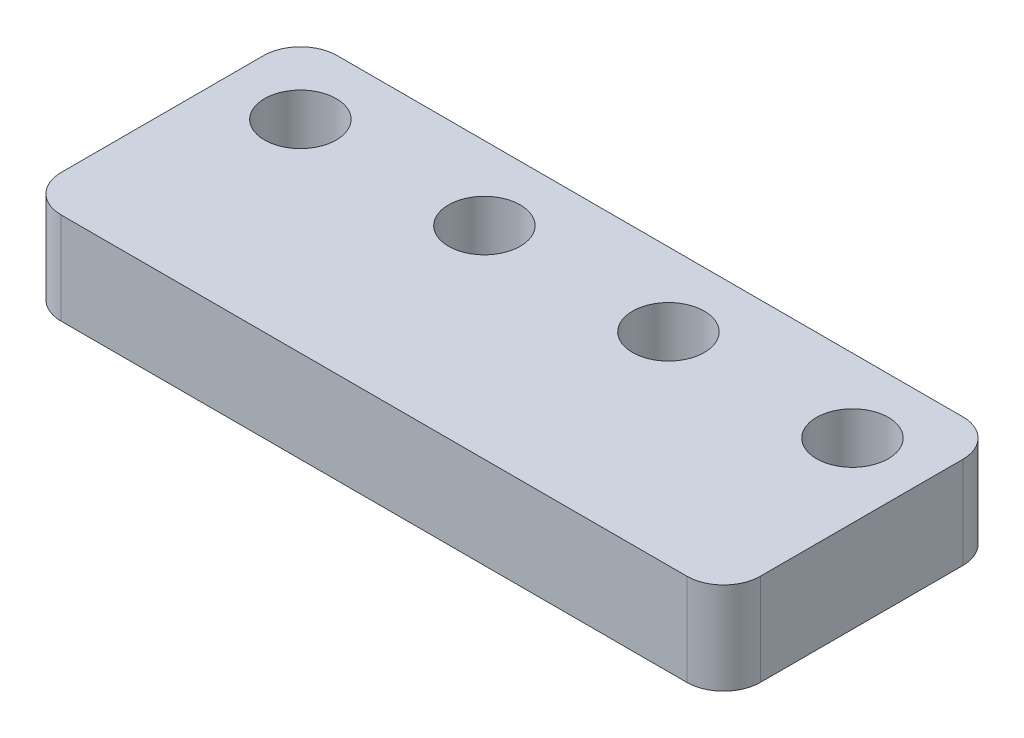
from build123d import *

# Parameters (mm, degrees)
BOSS_EXTRUDE1_DEPTH = 5
SKETCH2_R           = 1.95
CUT_EXTRUDE1_DEPTH  = 6


with BuildPart() as part:
    # Sketch1 → Boss-Extrude1 (new body)
    with BuildSketch(Plane(origin=(0, 0, 0), x_dir=(1, 0, 0), z_dir=(0, 1, 0))):
        with BuildLine():
            Line((-36, 0), (-2, 0))
            ThreePointArc((-2, 0), (-0.585786438, -0.585786438), (0, -2))
            Line((0, -2), (0, -13))
            ThreePointArc((0, -13), (-0.585786438, -14.414213562), (-2, -15))
            Line((-2, -15), (-36, -15))
            ThreePointArc((-36, -15), (-37.414213562, -14.414213562), (-38, -13))
            Line((-38, -13), (-38, -2))
            ThreePointArc((-38, -2), (-37.414213562, -0.585786438), (-36, 0))
        make_face()
    extrude(amount=BOSS_EXTRUDE1_DEPTH)

    # Sketch2 → Cut-Extrude1 (cut, through all)
    with BuildSketch(Plane(origin=(0, 5, 0), x_dir=(1, 0, 0), z_dir=(0, 1, 0))):
        with Locations((-4, -4)):
            Circle(SKETCH2_R)
        with Locations((-14, -4)):
            Circle(SKETCH2_R)
        with Locations((-24, -4)):
            Circle(SKETCH2_R)
        with Locations((-54, -4)):
            Circle(SKETCH2_R)
        with Locations((-34, -4)):
            Circle(SKETCH2_R)
        with Locations((-44, -4)):
            Circle(SKETCH2_R)
    extrude(amount=-CUT_EXTRUDE1_DEPTH, mode=Mode.SUBTRACT)


solid = part.part
